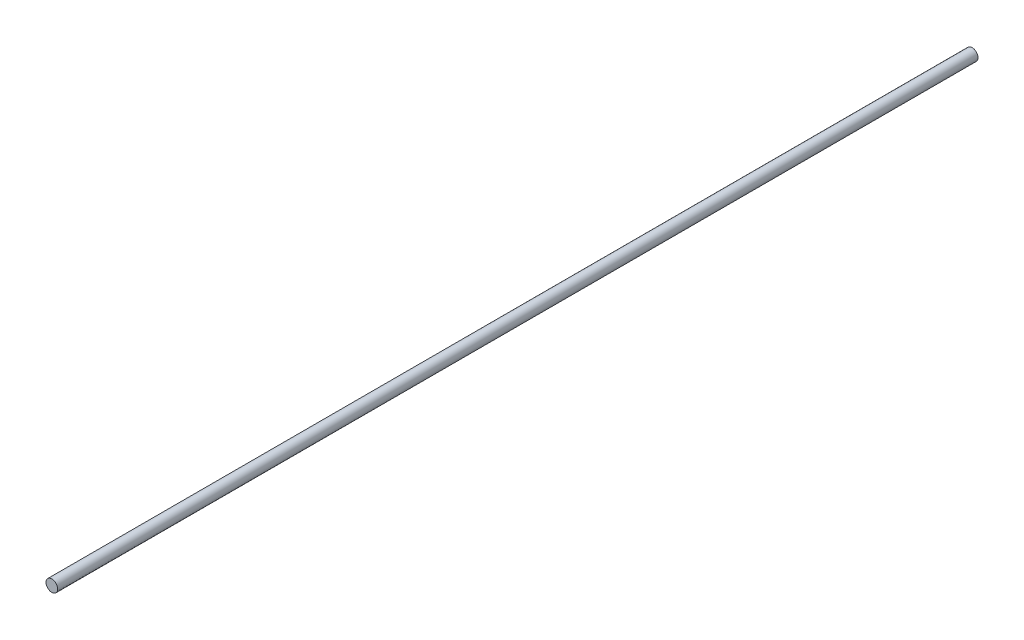
from build123d import *

# Parameters (mm, degrees)
SKETCH1_R           = 0.975
BOSS_EXTRUDE1_DEPTH = 153.75
SKETCH2_W           = 1
SKETCH2_H           = 1
CUT_EXTRUDE1_DEPTH  = 5


with BuildPart() as part:
    # Sketch1 → Boss-Extrude1 (new body)
    with BuildSketch(Plane.XY):
        Circle(SKETCH1_R)
    extrude(amount=BOSS_EXTRUDE1_DEPTH)

    # Sketch2 → Cut-Extrude1 (cut)
    with BuildSketch(Plane(origin=(0, 0, 0), x_dir=(-1, 0, 0), z_dir=(0, 0, -1))):
        Rectangle(SKETCH2_W, SKETCH2_H)
    extrude(amount=-CUT_EXTRUDE1_DEPTH, mode=Mode.SUBTRACT)


solid = part.part
